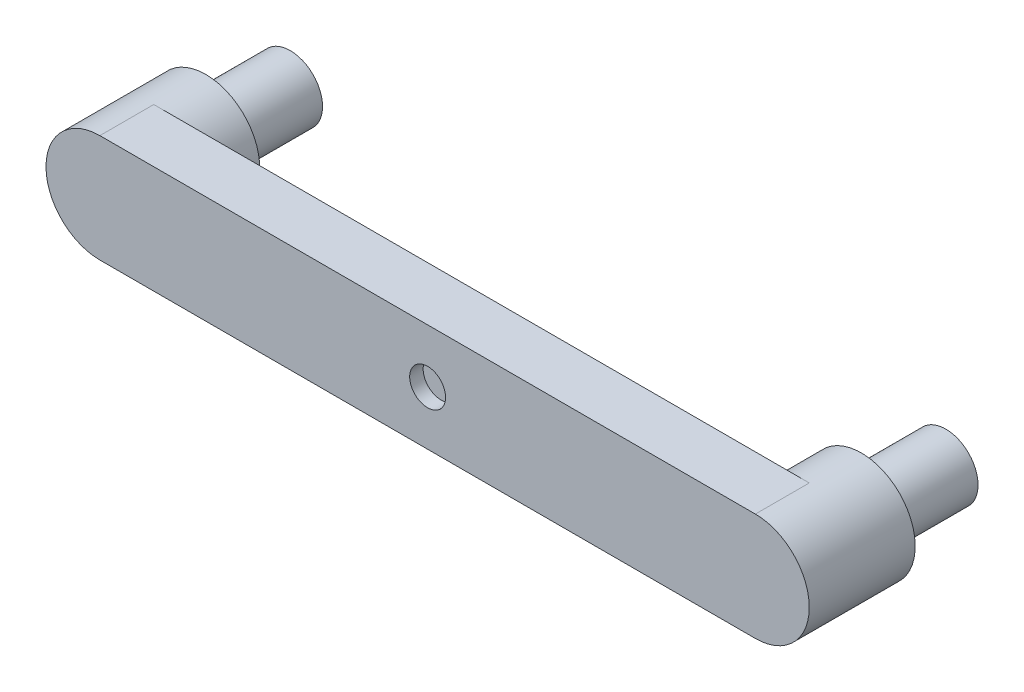
from build123d import *

# Parameters (mm, degrees)
BOSS_EXTRUDE1_DEPTH = 30
SKETCH2_R           = 30
BOSS_EXTRUDE2_DEPTH = 29
SKETCH1_3_R         = 10
CUT_EXTRUDE1_DEPTH  = 30
BOSS_EXTRUDE3_START = -59
SKETCH1_4_R         = 18
BOSS_EXTRUDE3_DEPTH = 47
SKETCH3_W           = 60
SKETCH3_H           = 15
CUT_EXTRUDE2_DEPTH  = 45


with BuildPart() as part:
    # Sketch1 → Boss-Extrude1 (new body)
    with BuildSketch(Plane.XY):
        with BuildLine():
            Line((-182.5, 30), (182.5, 30))
            ThreePointArc((182.5, 30), (212.5, 0), (182.5, -30))
            Line((182.5, -30), (-182.5, -30))
            ThreePointArc((-182.5, -30), (-212.5, 0), (-182.5, 30))
        make_face()
    extrude(amount=-BOSS_EXTRUDE1_DEPTH)

    # Sketch2 → Boss-Extrude2 (add)
    with BuildSketch(Plane(origin=(0, 0, -30), x_dir=(-1, 0, 0), z_dir=(0, 0, -1))):
        with Locations((-182.5, 0)):
            Circle(SKETCH2_R)
        with Locations((182.5, 0)):
            Circle(SKETCH2_R)
    extrude(amount=BOSS_EXTRUDE2_DEPTH)

    # Sketch1_3 → Cut-Extrude1 (cut)
    with BuildSketch(Plane.XY):
        Circle(SKETCH1_3_R)
    extrude(amount=-CUT_EXTRUDE1_DEPTH, mode=Mode.SUBTRACT)

    # Sketch1_4 → Boss-Extrude3 (add)
    with BuildSketch(Plane.XY.offset(BOSS_EXTRUDE3_START)):
        with Locations((182.5, 0)):
            Circle(SKETCH1_4_R)
        with Locations((-182.5, 0)):
            Circle(SKETCH1_4_R)
    extrude(amount=-BOSS_EXTRUDE3_DEPTH)

    # Sketch3 → Cut-Extrude2 (cut)
    with BuildSketch(Plane.XZ.offset(30)):
        with Locations((0, -15)):
            Rectangle(SKETCH3_W, SKETCH3_H)
    extrude(amount=-CUT_EXTRUDE2_DEPTH, mode=Mode.SUBTRACT)


solid = part.part
